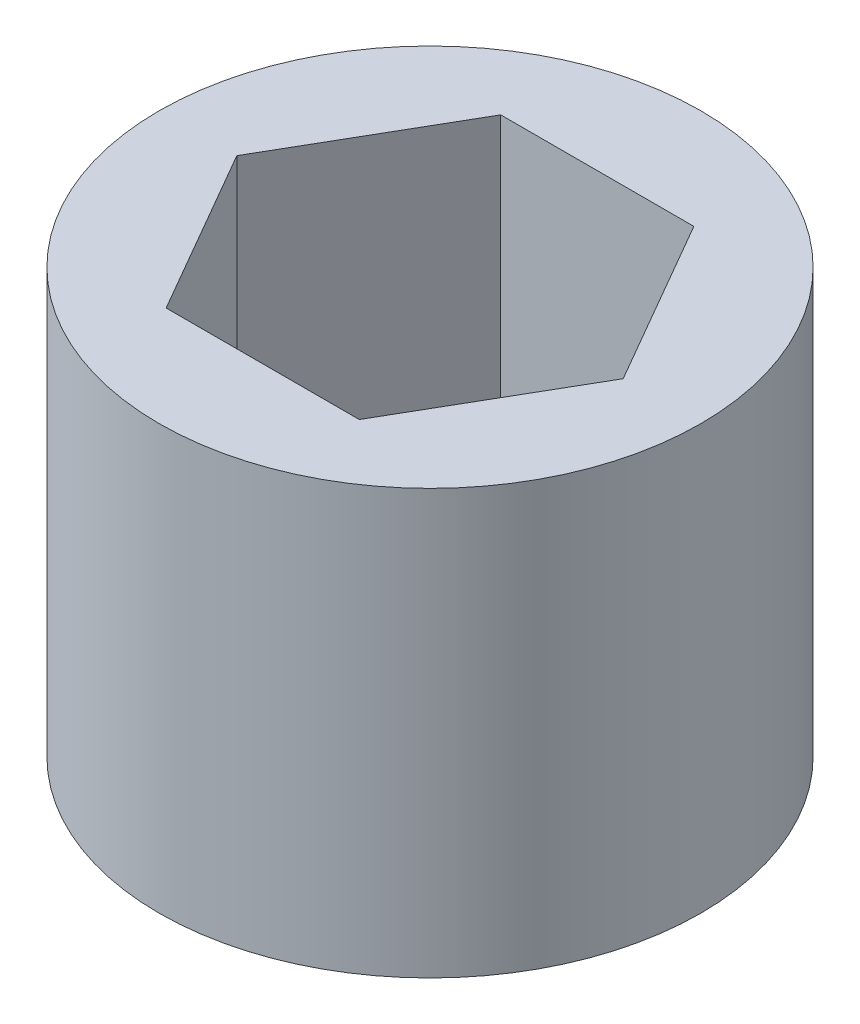
from build123d import *

# Parameters (mm, degrees)
SKETCH1_R           = 5.75
SKETCH1_R_2         = 4.1
BOSS_EXTRUDE1_DEPTH = 9


with BuildPart() as part:
    # Sketch1 → Boss-Extrude1 (new body)
    with BuildSketch(Plane(origin=(0, 0, 0), x_dir=(1, 0, 0), z_dir=(0, 1, 0))):
        with Locations(Location((0, 0, 0), (0, 0, 270))):
            Circle(SKETCH1_R)
        Circle(SKETCH1_R_2, mode=Mode.SUBTRACT)
        with BuildLine():
            ThreePointArc((-2.05, -3.550704156), (0, -4.1), (2.05, -3.550704156))
            Line((2.05, -3.550704156), (-2.05, -3.550704156))
        make_face()
        with BuildLine():
            Line((4.1, 0), (2.05, -3.550704156))
            ThreePointArc((2.05, -3.550704156), (3.550704156, -2.05), (4.1, 0))
        make_face()
        with BuildLine():
            Line((2.05, 3.550704156), (4.1, 0))
            ThreePointArc((4.1, 0), (3.550704156, 2.05), (2.05, 3.550704156))
        make_face()
        with BuildLine():
            Line((-2.05, 3.550704156), (2.05, 3.550704156))
            ThreePointArc((2.05, 3.550704156), (0, 4.1), (-2.05, 3.550704156))
        make_face()
        with BuildLine():
            ThreePointArc((-2.05, 3.550704156), (-3.550704156, 2.05), (-4.1, 0))
            Line((-4.1, 0), (-2.05, 3.550704156))
        make_face()
        with BuildLine():
            ThreePointArc((-4.1, 0), (-3.550704156, -2.05), (-2.05, -3.550704156))
            Line((-2.05, -3.550704156), (-4.1, 0))
        make_face()
    extrude(amount=BOSS_EXTRUDE1_DEPTH)


solid = part.part
